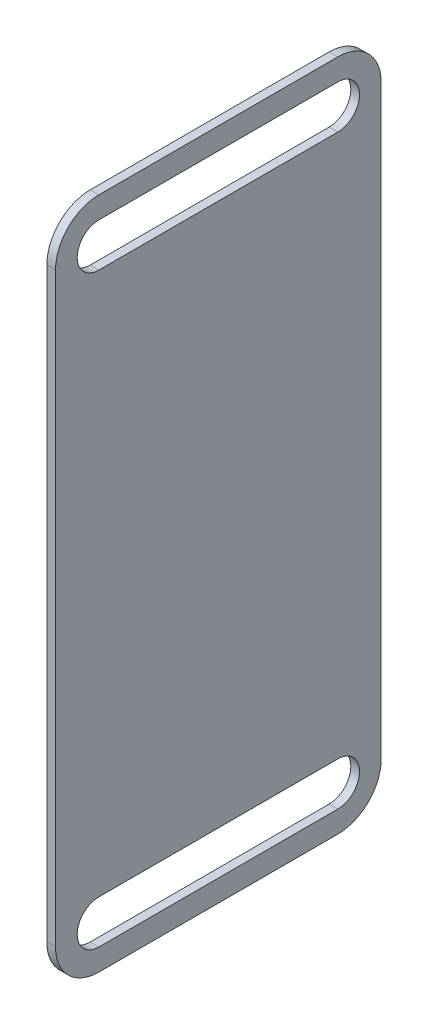
from build123d import *

# Parameters (mm, degrees)
BOSS_EXTRUDE1_DEPTH = 2.54


with BuildPart() as part:
    # Sketch1 → Boss-Extrude1 (new body)
    with BuildSketch(Plane(origin=(0, 0, 0), x_dir=(0, 0, -1), z_dir=(1, 0, 0))):
        with BuildLine():
            Line((12.7, 0), (82.55, 0))
            ThreePointArc((82.55, 0), (91.530256121, 3.719743879), (95.25, 12.7))
            Line((95.25, 12.7), (95.25, 184.15))
            ThreePointArc((95.25, 184.15), (91.530256121, 193.130256121), (82.55, 196.85))
            Line((82.55, 196.85), (12.7, 196.85))
            ThreePointArc((12.7, 196.85), (3.719743879, 193.130256121), (0, 184.15))
            Line((0, 184.15), (0, 12.7))
            ThreePointArc((0, 12.7), (3.719743879, 3.719743879), (12.7, 0))
        make_face()
        with BuildLine():
            Line((82.55, 6.35), (12.7, 6.35))
            ThreePointArc((12.7, 6.35), (6.35, 12.7), (12.7, 19.05))
            Line((12.7, 19.05), (82.55, 19.05))
            ThreePointArc((82.55, 19.05), (88.9, 12.7), (82.55, 6.35))
        make_face(mode=Mode.SUBTRACT)
        with BuildLine():
            Line((82.55, 177.8), (12.7, 177.8))
            ThreePointArc((12.7, 177.8), (6.35, 184.15), (12.7, 190.5))
            Line((12.7, 190.5), (82.55, 190.5))
            ThreePointArc((82.55, 190.5), (88.9, 184.15), (82.55, 177.8))
        make_face(mode=Mode.SUBTRACT)
    extrude(amount=BOSS_EXTRUDE1_DEPTH)


solid = part.part
